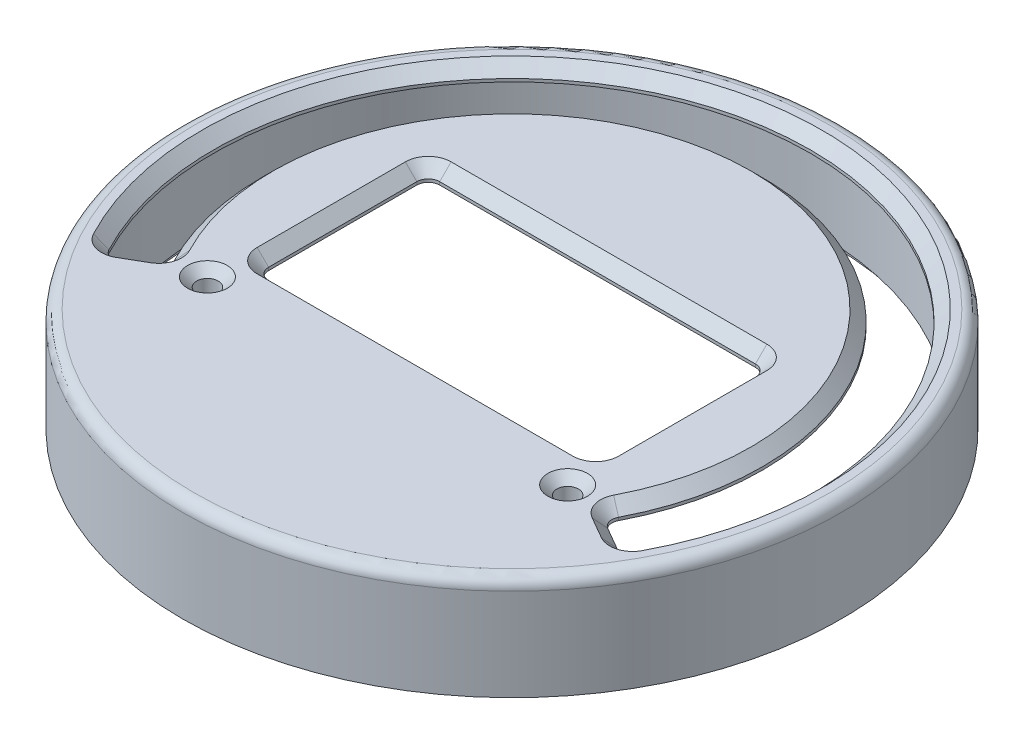
from build123d import *

# Parameters (mm, degrees)
SKETCH1_R                                       = 36.59505
SKETCH1_W                                       = 37.6
SKETCH1_H                                       = 19
BOSS_EXTRUDE1_DEPTH                             = 1.6
BOSS_EXTRUDE2_START                             = 8.3058
SKETCH2_R                                       = 36.59505
SKETCH2_R_2                                     = 34.1249
SKETCH2_R_3                                     = 2.2225
BOSS_EXTRUDE2_DEPTH                             = 8.3058
CSK_FOR_M2_FLAT_HEAD_MACHINE_SCREW1_D           = 2.4
CSK_FOR_M2_FLAT_HEAD_MACHINE_SCREW1_CSINK_D     = 4.4
CSK_FOR_M2_FLAT_HEAD_MACHINE_SCREW1_CSINK_ANGLE = 90
FILLET1_R                                       = 1.27
BOSS_EXTRUDE3_START                             = 1.6
SKETCH5_R                                       = 36.59505
SKETCH5_R_2                                     = 35.3949
BOSS_EXTRUDE3_DEPTH                             = 1.6
CHAMFER2_SIZE                                   = 1.27
FILLET2_R                                       = 1.27


with BuildPart() as part:
    # Sketch1 → Boss-Extrude1 (new body)
    with BuildSketch(Plane(origin=(0, 0, 0), x_dir=(1, 0, 0), z_dir=(0, 1, 0))):
        with Locations(Location((0, 0, 0), (0, 0, 270))):
            Circle(SKETCH1_R)
        with BuildLine():
            Line((-28.706144728, -16.573500386), (-24.086765224, -13.906500386))
            ThreePointArc((-24.086765224, -13.906500386), (0, 27.813000772), (24.086765224, -13.906500386))
            Line((24.086765224, -13.906500386), (28.706144728, -16.573500386))
            ThreePointArc((28.706144728, -16.573500386), (0, 33.147000772), (-28.706144728, -16.573500386))
        make_face(mode=Mode.SUBTRACT)
        Rectangle(SKETCH1_W, SKETCH1_H, mode=Mode.SUBTRACT)
    extrude(amount=BOSS_EXTRUDE1_DEPTH)

    # Sketch2 → Boss-Extrude2 (add)
    # profile 1 of 3: a face of its own
    with BuildSketch(Plane.XZ.offset(BOSS_EXTRUDE2_START)):
        with Locations(Location((0, 0, 0), (0, 0, 270))):
            Circle(SKETCH2_R)
        with Locations(Location((0, 0, 0), (0, 0, 270))):
            Circle(SKETCH2_R_2, mode=Mode.SUBTRACT)
    # profile 2 of 3: a face of its own
    with BuildSketch(Plane.XZ.offset(BOSS_EXTRUDE2_START)):
        with Locations(Location((20, 13.82014, 0), (0, 0, 90))):
            Circle(SKETCH2_R_3)
    # profile 3 of 3: a face of its own
    with BuildSketch(Plane.XZ.offset(BOSS_EXTRUDE2_START)):
        with Locations(Location((-20, 13.82014, 0), (0, 0, 90))):
            Circle(SKETCH2_R_3)
    extrude(amount=-BOSS_EXTRUDE2_DEPTH)

    # CSK for M2 Flat Head Machine Screw1 (through all)
    with Locations(Plane(origin=(0, 1.6, 0), x_dir=(1, 0, 0), z_dir=(0, 1, 0))):
        with Locations((-20, -13.82014), (20, -13.82014)):
            CounterSinkHole(CSK_FOR_M2_FLAT_HEAD_MACHINE_SCREW1_D / 2, CSK_FOR_M2_FLAT_HEAD_MACHINE_SCREW1_CSINK_D / 2, counter_sink_angle=CSK_FOR_M2_FLAT_HEAD_MACHINE_SCREW1_CSINK_ANGLE)

    # Fillet1
    fillet1_edges = [part.edges().sort_by_distance(p)[0] for p in [
        (28.706144728, 0.8, 16.573500386),
        (-28.706144728, 0.8, 16.573500386),
        (-24.086765224, 0.8, 13.906500386),
        (24.086765224, 0.8, 13.906500386),
        (18.8, 0.8, -9.5),
        (-18.8, 0.8, -9.5),
        (-18.8, 0.8, 9.5),
        (18.8, 0.8, 9.5),
    ]]
    fillet(fillet1_edges, radius=FILLET1_R)

    # Sketch5 → Boss-Extrude3 (add)
    with BuildSketch(Plane.XZ.offset(8.3058).offset(BOSS_EXTRUDE3_START)):
        with Locations(Location((0, 0, 0), (0, 0, 270))):
            Circle(SKETCH5_R)
        with Locations(Location((0, 0, 0), (0, 0, 270))):
            Circle(SKETCH5_R_2, mode=Mode.SUBTRACT)
    extrude(amount=-BOSS_EXTRUDE3_DEPTH)

    # Chamfer2
    chamfer2_edges = [part.edges().sort_by_distance(p)[0] for p in [
        (-18.8, 1.6, 0),
        (0, 1.6, 9.5),
        (18.8, 1.6, 0),
        (0, 1.6, -9.5),
        (0, 1.6, -27.813000772),
        (26.373483072, 1.6, 15.226737551),
        (0, 1.6, -33.147000772),
        (-26.373483072, 1.6, 15.226737551),
        (-18.428025612, 1.6, 9.128025612),
        (18.428025612, 1.6, 9.128025612),
        (18.428025612, 1.6, -9.128025612),
        (-18.428025612, 1.6, -9.128025612),
        (24.57833714, 1.6, 13.783189465),
        (28.572450915, 1.6, 16.04592687),
        (-28.572450915, 1.6, 16.04592687),
        (-24.57833714, 1.6, 13.783189465),
    ]]
    chamfer(chamfer2_edges, length=CHAMFER2_SIZE)

    # Fillet2
    fillet2_edges = [part.edges().sort_by_distance(p)[0] for p in [
        (0, 1.6, -36.59505),
    ]]
    fillet(fillet2_edges, radius=FILLET2_R)


solid = part.part
